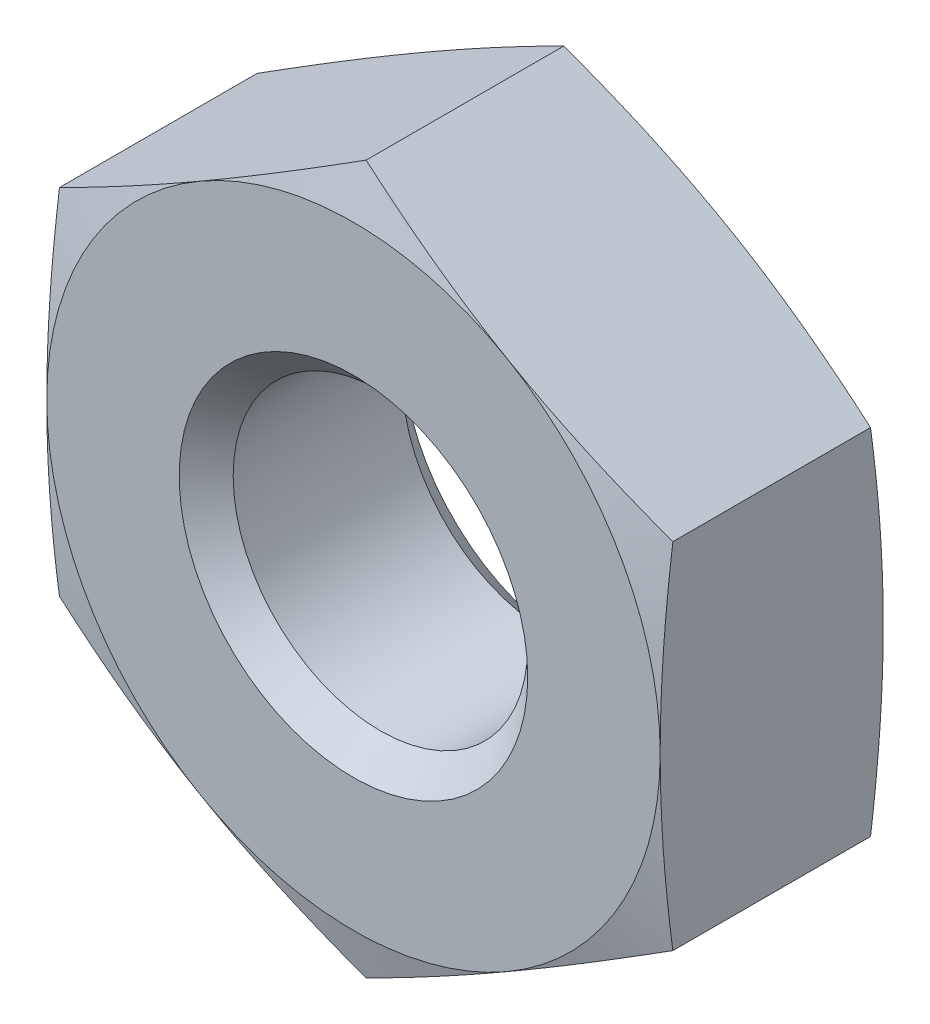
from build123d import *

# Parameters (mm, degrees)
SKETCH2_W          = 22.352
SKETCH2_H          = 22.352
CUT_EXTRUDE1_DEPTH = 4.064


with BuildPart() as part:
    # Sketch1 → Revolve1 (revolve)
    with BuildSketch(Plane(origin=(0, 0, 0), x_dir=(0, 0, -1), z_dir=(1, 0, 0))):
        Polygon((0, 0), (0, 5.588), (0.299460017, 6.7056), (3.764539983, 6.7056), (4.064, 5.588), (4.064, 0), align=None)
    revolve(axis=Axis((0, 0, -4.064), (0, 0, 1)))

    # Sketch2 → Cut-Extrude1 (cut)
    with BuildSketch(Plane.XY):
        Rectangle(SKETCH2_W, SKETCH2_H)
        Polygon((-5.588, 3.226233304), (-5.588, -3.226233304), (0, -6.452466608), (5.588, -3.226233304), (5.588, 3.226233304), (0, 6.452466608), align=None, mode=Mode.SUBTRACT)
    extrude(amount=-CUT_EXTRUDE1_DEPTH, mode=Mode.SUBTRACT)

    # Sketch3 → Cut-Revolve1 (revolve, cut)
    with BuildSketch(Plane(origin=(0, 0, 0), x_dir=(0, 0, -1), z_dir=(1, 0, 0))):
        Polygon((0, 0), (0, 3.175), (0.49149, 2.68351), (3.57251, 2.68351), (4.064, 3.175), (4.064, 0), align=None)
    revolve(axis=Axis((0, 0, -4.064), (0, 0, 1)), mode=Mode.SUBTRACT)


solid = part.part
